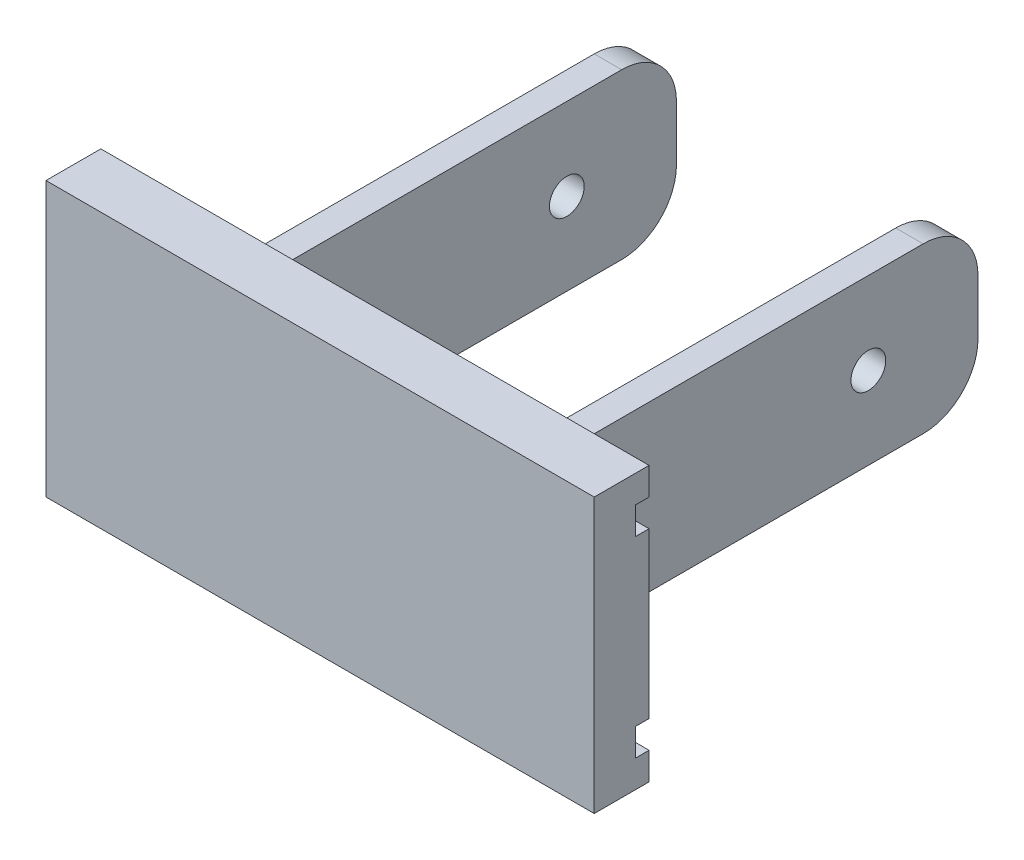
from build123d import *

# Parameters (mm, degrees)
SKETCH1_W               = 100
SKETCH1_H               = 50
BOSS_EXTRUDE1_DEPTH     = 10
SKETCH2_W               = 2.5
SKETCH2_H               = 5
CUT_EXTRUDE1_DEPTH      = 1
CUT_EXTRUDE1_DEPTH_BACK = 101
SKETCH4_W               = 5
SKETCH4_H               = 30
BOSS_EXTRUDE2_DEPTH     = 80
SKETCH5_R               = 3.173204402
CUT_EXTRUDE3_DEPTH      = 21
CUT_EXTRUDE3_DEPTH_BACK = 81
FILLET1_R               = 10
FILLET2_R               = 10


with BuildPart() as part:
    # Sketch1 → Boss-Extrude1 (new body)
    with BuildSketch(Plane.XY):
        with Locations((50, 25)):
            Rectangle(SKETCH1_W, SKETCH1_H)
    extrude(amount=BOSS_EXTRUDE1_DEPTH)

    # Sketch2 → Cut-Extrude1 (cut, two sides)
    with BuildSketch(Plane.ZY) as cut_extrude1_sk:
        with Locations((1.25, 42.5)):
            Rectangle(SKETCH2_W, SKETCH2_H)
        with Locations((1.25, 7.5)):
            Rectangle(SKETCH2_W, SKETCH2_H)
    extrude(amount=CUT_EXTRUDE1_DEPTH, mode=Mode.SUBTRACT)
    extrude(cut_extrude1_sk.sketch, amount=-CUT_EXTRUDE1_DEPTH_BACK, mode=Mode.SUBTRACT)

    # Sketch4 → Boss-Extrude2 (add)
    with BuildSketch(Plane(origin=(0, 0, 0), x_dir=(-1, 0, 0), z_dir=(0, 0, -1))):
        with Locations((-77.5, 25)):
            Rectangle(SKETCH4_W, SKETCH4_H)
        with Locations((-22.5, 25)):
            Rectangle(SKETCH4_W, SKETCH4_H)
    extrude(amount=BOSS_EXTRUDE2_DEPTH)

    # Sketch5 → Cut-Extrude3 (cut, two sides)
    with BuildSketch(Plane(origin=(80, 0, 0), x_dir=(0, 0, -1), z_dir=(1, 0, 0))) as cut_extrude3_sk:
        with Locations((60, 25)):
            Circle(SKETCH5_R)
    extrude(amount=CUT_EXTRUDE3_DEPTH, mode=Mode.SUBTRACT)
    extrude(cut_extrude3_sk.sketch, amount=-CUT_EXTRUDE3_DEPTH_BACK, mode=Mode.SUBTRACT)

    # Fillet1
    fillet1_edges = [part.edges().sort_by_distance(p)[0] for p in [
        (77.5, 40, -80),
        (77.5, 10, -80),
        (22.5, 10, -80),
        (22.5, 40, -80),
    ]]
    fillet(fillet1_edges, radius=FILLET1_R)

    # Fillet2
    fillet2_edges = [part.edges().sort_by_distance(p)[0] for p in [
        (80, 25, 0),
        (20, 25, 0),
    ]]
    fillet(fillet2_edges, radius=FILLET2_R)


solid = part.part
